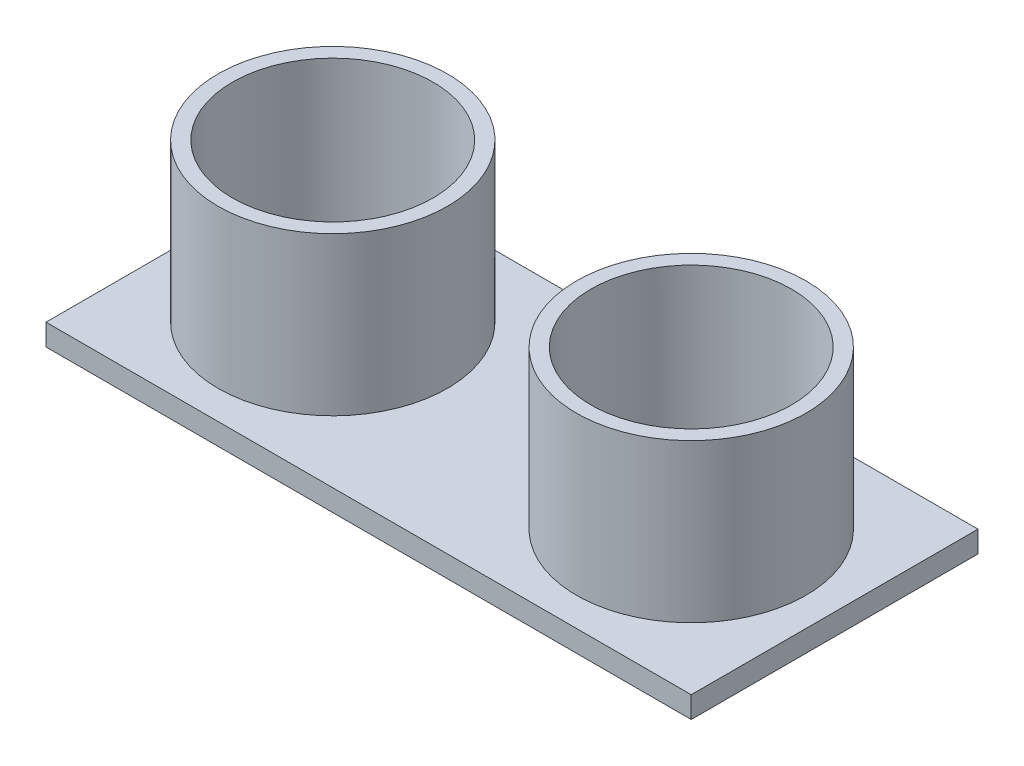
from build123d import *

# Parameters (mm, degrees)
SKETCH1_W           = 45
SKETCH1_H           = 20
BOSS_EXTRUDE1_DEPTH = 1.5
SKETCH3_R           = 8
SKETCH3_R_2         = 7
BOSS_EXTRUDE2_DEPTH = 11


with BuildPart() as part:
    # Sketch1 → Boss-Extrude1 (new body)
    with BuildSketch(Plane(origin=(0, 0, 0), x_dir=(1, 0, 0), z_dir=(0, 1, 0))):
        Rectangle(SKETCH1_W, SKETCH1_H)
    extrude(amount=BOSS_EXTRUDE1_DEPTH)

    # Sketch3 → Boss-Extrude2 (add)
    with BuildSketch(Plane(origin=(0, 1.5, 0), x_dir=(1, 0, 0), z_dir=(0, 1, 0))):
        with Locations((-12.5, 0)):
            Circle(SKETCH3_R)
        with Locations((-12.5, 0)):
            Circle(SKETCH3_R_2, mode=Mode.SUBTRACT)
        with Locations((12.5, 0)):
            Circle(SKETCH3_R)
        with Locations((12.5, 0)):
            Circle(SKETCH3_R_2, mode=Mode.SUBTRACT)
    extrude(amount=BOSS_EXTRUDE2_DEPTH)


solid = part.part
